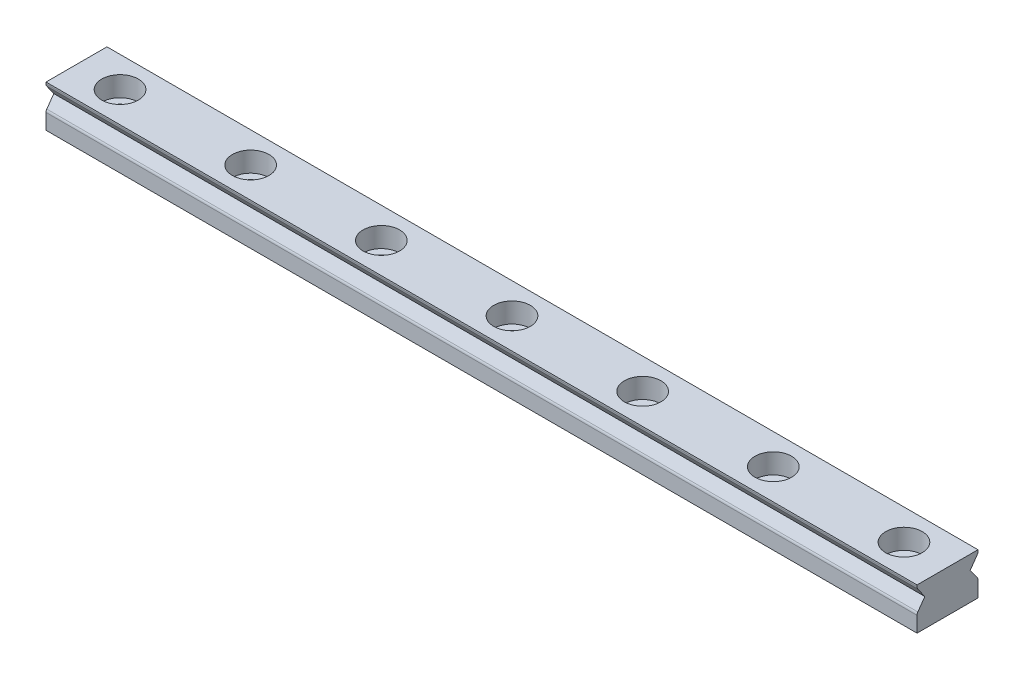
from build123d import *

# Parameters (mm, degrees)
SKETCH_1_W             = 100
SKETCH_1_H             = 4.8
EXTRUDE_1_DEPTH        = 3.5
SKETCH_3_R             = 2.1
CUT_EXTRUDE_1_DEPTH    = 2.3
SKETCH_4_R             = 1.2
CUT_EXTRUDE_2_DEPTH    = 2.5
CUT_EXTRUDE_START      = -101
CUT_EXTRUDE_4_DEPTH    = 102
PATTERN_LINEAR_1_COUNT = 6
PATTERN_LINEAR_1_PITCH = 15


with BuildPart() as part:
    # 草图1 → 凸台-拉伸1 (new body, symmetric)
    with BuildSketch(Plane.XY):
        Rectangle(SKETCH_1_W, SKETCH_1_H)
    extrude(amount=EXTRUDE_1_DEPTH, both=True)

    # 草图3 → 切除-拉伸1 (cut)
    with BuildSketch(Plane(origin=(0, 2.4, 0), x_dir=(1, 0, 0), z_dir=(0, 1, 0))):
        with Locations((-45, 0)):
            Circle(SKETCH_3_R)
    cut_extrude_1 = extrude(amount=-CUT_EXTRUDE_1_DEPTH, mode=Mode.SUBTRACT)

    # 草图4 → 切除-拉伸2 (cut)
    with BuildSketch(Plane(origin=(0, 0.1, 0), x_dir=(1, 0, 0), z_dir=(0, 1, 0))):
        with Locations((-45, 0)):
            Circle(SKETCH_4_R)
    cut_extrude_2 = extrude(amount=-CUT_EXTRUDE_2_DEPTH, mode=Mode.SUBTRACT)

    # 镜向1: 切除-拉伸1, 切除-拉伸2 across plane
    add(cut_extrude_1.mirror(Plane(origin=(0, 0, 0), x_dir=(0, 0, 1), z_dir=(1, 0, 0))), mode=Mode.SUBTRACT)
    add(cut_extrude_2.mirror(Plane(origin=(0, 0, 0), x_dir=(0, 0, 1), z_dir=(1, 0, 0))), mode=Mode.SUBTRACT)

    # 草图6 → 切除-拉伸4 (cut)
    with BuildSketch(Plane.ZY.offset(50).offset(CUT_EXTRUDE_START)):
        with BuildLine():
            Line((3.5, 29.375276139), (3.5, 2.4))
            Line((3.5, 2.4), (3.5, 2.223915661))
            ThreePointArc((3.5, 2.223915661), (3.476466019, 2.072323667), (3.408079469, 1.935001925))
            Line((3.408079469, 1.935001925), (2.604516262, 0.8))
            Line((2.604516262, 0.8), (3.408079469, -0.335001925))
            ThreePointArc((3.408079469, -0.335001925), (3.476466019, -0.472323667), (3.5, -0.623915661))
            Line((3.5, -0.623915661), (3.5, -27.5991918))
            Line((3.5, -27.5991918), (57.450552278, -27.5991918))
            Line((57.450552278, -27.5991918), (57.450552278, 29.375276139))
            Line((57.450552278, 29.375276139), (3.5, 29.375276139))
        make_face()
    cut_extrude_4 = extrude(amount=CUT_EXTRUDE_4_DEPTH, mode=Mode.SUBTRACT)

    # 镜向3: 切除-拉伸4 across plane
    add(cut_extrude_4.mirror(Plane.XY), mode=Mode.SUBTRACT)

    # 阵列(线性)1: 切除-拉伸1, 切除-拉伸2 ×6
    with Locations(*[(i * PATTERN_LINEAR_1_PITCH, 0, 0) for i in range(1, PATTERN_LINEAR_1_COUNT)]):
        add(cut_extrude_1, mode=Mode.SUBTRACT)
        add(cut_extrude_2, mode=Mode.SUBTRACT)


solid = part.part
